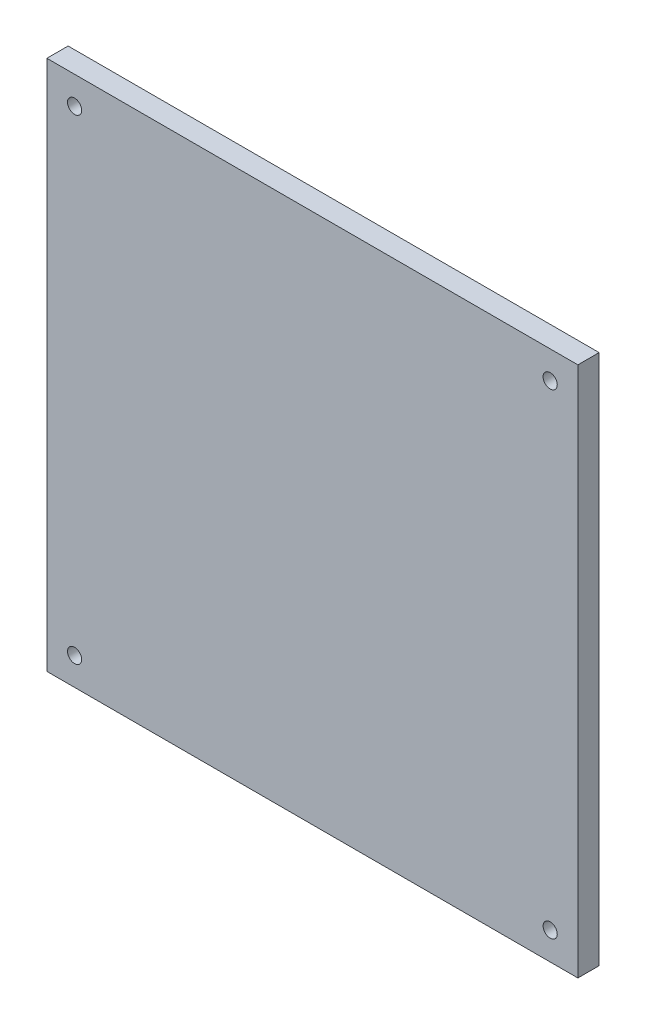
from build123d import *

# Parameters (mm, degrees)
SKETCH1_W           = 150
SKETCH1_H           = 150
BOSS_EXTRUDE1_DEPTH = 6
SKETCH2_R           = 2
CUT_EXTRUDE1_DEPTH  = 10


with BuildPart() as part:
    # Sketch1 → Boss-Extrude1 (new body)
    with BuildSketch(Plane.XY):
        Rectangle(SKETCH1_W, SKETCH1_H)
    extrude(amount=BOSS_EXTRUDE1_DEPTH)

    # Sketch2 → Cut-Extrude1 (cut)
    with BuildSketch(Plane.XY.offset(6)):
        with Locations((67.175144213, 67.175144213)):
            Circle(SKETCH2_R)
        with Locations((67.175144213, -67.175144213)):
            Circle(SKETCH2_R)
        with Locations((-67.175144213, -67.175144213)):
            Circle(SKETCH2_R)
        with Locations((-67.175144213, 67.175144213)):
            Circle(SKETCH2_R)
    extrude(amount=-CUT_EXTRUDE1_DEPTH, mode=Mode.SUBTRACT)


solid = part.part
